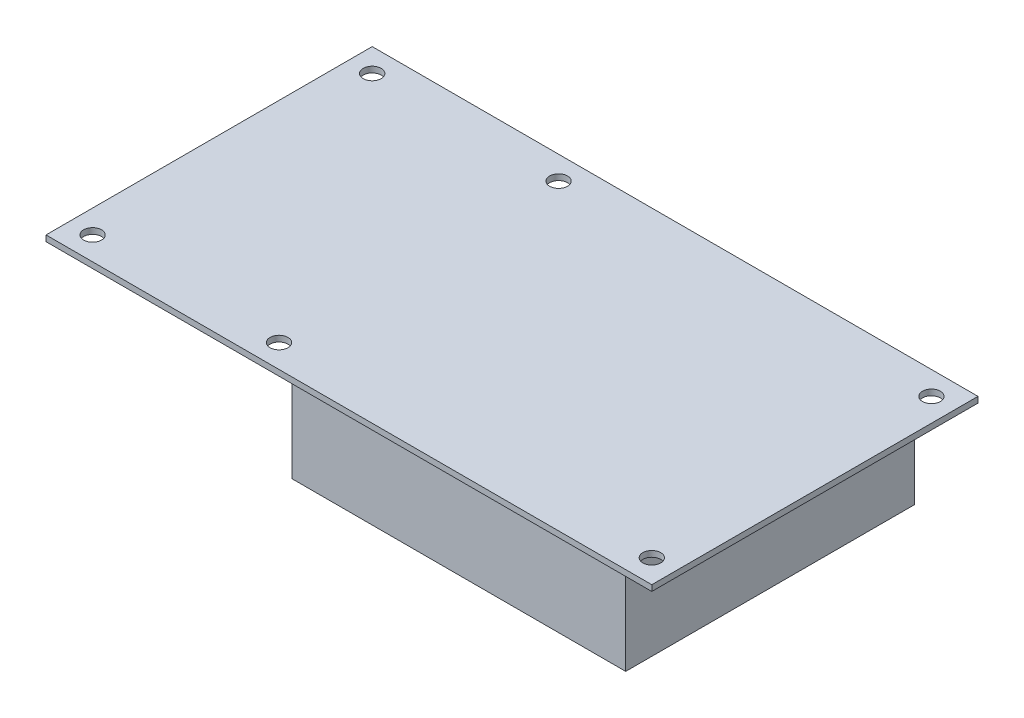
from build123d import *

# Parameters (mm, degrees)
SKETCH1_W          = 165.1
SKETCH1_H          = 88.9
EXTRUDE1_DEPTH     = 1.6002
SKETCH2_R          = 2.4384
CUT_EXTRUDE1_DEPTH = 2.6002
SKETCH3_W          = 90.932
SKETCH3_H          = 78.74
EXTRUDE2_DEPTH     = 27.0002


with BuildPart() as part:
    # Sketch1 → Extrude1 (new body)
    with BuildSketch(Plane(origin=(0, 0, 0), x_dir=(1, 0, 0), z_dir=(0, 1, 0))):
        with Locations((82.55, 44.45)):
            Rectangle(SKETCH1_W, SKETCH1_H)
    extrude(amount=EXTRUDE1_DEPTH)

    # Sketch2 → Cut-Extrude1 (cut, through all)
    with BuildSketch(Plane(origin=(0, 1.6002, 0), x_dir=(-1, 0, 0), z_dir=(0, 1, 0))):
        with Locations((-158.75, -6.35)):
            Circle(SKETCH2_R)
        with Locations((-57.15, -6.35)):
            Circle(SKETCH2_R)
        with Locations((-6.35, -6.35)):
            Circle(SKETCH2_R)
        with Locations((-158.75, -82.55)):
            Circle(SKETCH2_R)
        with Locations((-57.15, -82.55)):
            Circle(SKETCH2_R)
        with Locations((-6.35, -82.55)):
            Circle(SKETCH2_R)
    extrude(amount=-CUT_EXTRUDE1_DEPTH, mode=Mode.SUBTRACT)

    # Sketch3 → Extrude2 (add)
    with BuildSketch(Plane.XZ):
        with Locations((107.95, -43.942)):
            Rectangle(SKETCH3_W, SKETCH3_H)
    extrude(amount=EXTRUDE2_DEPTH)


solid = part.part
